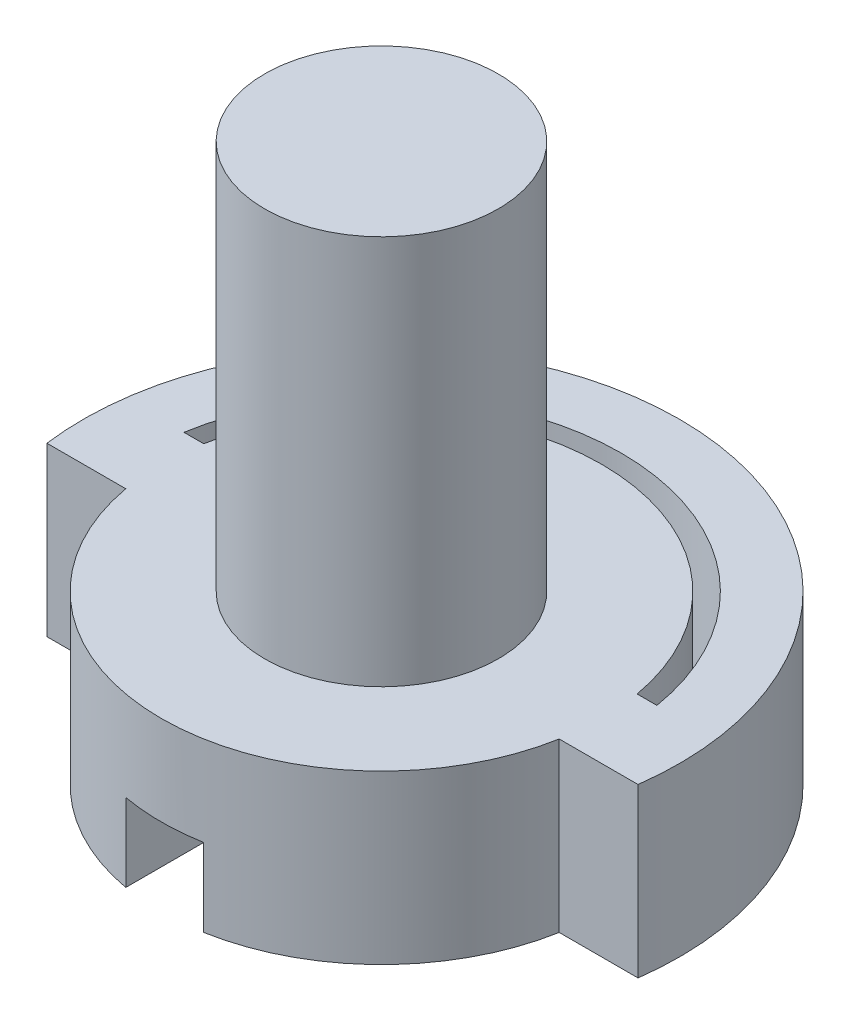
from build123d import *

# Parameters (mm, degrees)
BOSS_EXTRUDE1_DEPTH = 4.3
SKETCH2_R           = 3
BOSS_EXTRUDE2_DEPTH = 10
SKETCH3_W           = 2
SKETCH3_H           = 11.870992598
CUT_EXTRUDE1_DEPTH  = 2


with BuildPart() as part:
    # Sketch1 → Boss-Extrude1 (new body)
    with BuildSketch(Plane(origin=(0, 0, 0), x_dir=(1, 0, 0), z_dir=(0, 1, 0))):
        with BuildLine():
            Line((5.560800302, -1), (-5.560800302, -1))
            ThreePointArc((-5.560800302, -1), (0, -5.65), (5.560800302, -1))
        make_face()
        with BuildLine():
            Line((5.560800302, 1), (-5.560800302, 1))
            ThreePointArc((-5.560800302, 1), (-5.65, 0), (-5.560800302, -1))
            Line((-5.560800302, -1), (5.560800302, -1))
            ThreePointArc((5.560800302, -1), (5.627655893, -0.501985205), (5.65, 0))
            ThreePointArc((5.65, 0), (5.627655893, 0.501985205), (5.560800302, 1))
        make_face()
        with BuildLine():
            ThreePointArc((5.560800302, 1), (0, 5.65), (-5.560800302, 1))
            Line((-5.560800302, 1), (5.560800302, 1))
        make_face()
        with BuildLine():
            Line((-5.560800302, 1), (-6.068154579, 1))
            ThreePointArc((-6.068154579, 1), (-6.15, 0), (-6.068154579, -1))
            Line((-6.068154579, -1), (-5.560800302, -1))
            ThreePointArc((-5.560800302, -1), (-5.65, 0), (-5.560800302, 1))
        make_face()
        with BuildLine():
            ThreePointArc((6.15, 0), (6.129504493, 0.501671873), (6.068154579, 1))
            Line((6.068154579, 1), (5.560800302, 1))
            ThreePointArc((5.560800302, 1), (5.627655893, 0.501985205), (5.65, 0))
            ThreePointArc((5.65, 0), (5.627655893, -0.501985205), (5.560800302, -1))
            Line((5.560800302, -1), (6.068154579, -1))
            ThreePointArc((6.068154579, -1), (6.129504493, -0.501671873), (6.15, 0))
        make_face()
        with BuildLine():
            Line((-6.068154579, 1), (-7.584358905, 1))
            ThreePointArc((-7.584358905, 1), (-7.65, 0), (-7.584358905, -1))
            Line((-7.584358905, -1), (-6.068154579, -1))
            ThreePointArc((-6.068154579, -1), (-6.15, 0), (-6.068154579, 1))
        make_face()
        with BuildLine():
            ThreePointArc((7.65, 0), (7.633572087, 0.50107603), (7.584358905, 1))
            Line((7.584358905, 1), (6.068154579, 1))
            ThreePointArc((6.068154579, 1), (6.129504493, 0.501671873), (6.15, 0))
            ThreePointArc((6.15, 0), (6.129504493, -0.501671873), (6.068154579, -1))
            Line((6.068154579, -1), (7.584358905, -1))
            ThreePointArc((7.584358905, -1), (7.633572087, -0.50107603), (7.65, 0))
        make_face()
        with BuildLine():
            ThreePointArc((7.584358905, 1), (0, 7.65), (-7.584358905, 1))
            Line((-7.584358905, 1), (-6.068154579, 1))
            ThreePointArc((-6.068154579, 1), (0, 6.15), (6.068154579, 1))
            Line((6.068154579, 1), (7.584358905, 1))
        make_face()
    extrude(amount=BOSS_EXTRUDE1_DEPTH)

    # Sketch2 → Boss-Extrude2 (add)
    with BuildSketch(Plane(origin=(0, 4.3, 0), x_dir=(1, 0, 0), z_dir=(0, 1, 0))):
        Circle(SKETCH2_R)
    extrude(amount=BOSS_EXTRUDE2_DEPTH)

    # Sketch3 → Cut-Extrude1 (cut)
    with BuildSketch(Plane.XZ):
        Rectangle(SKETCH3_W, SKETCH3_H)
    extrude(amount=-CUT_EXTRUDE1_DEPTH, mode=Mode.SUBTRACT)


solid = part.part
